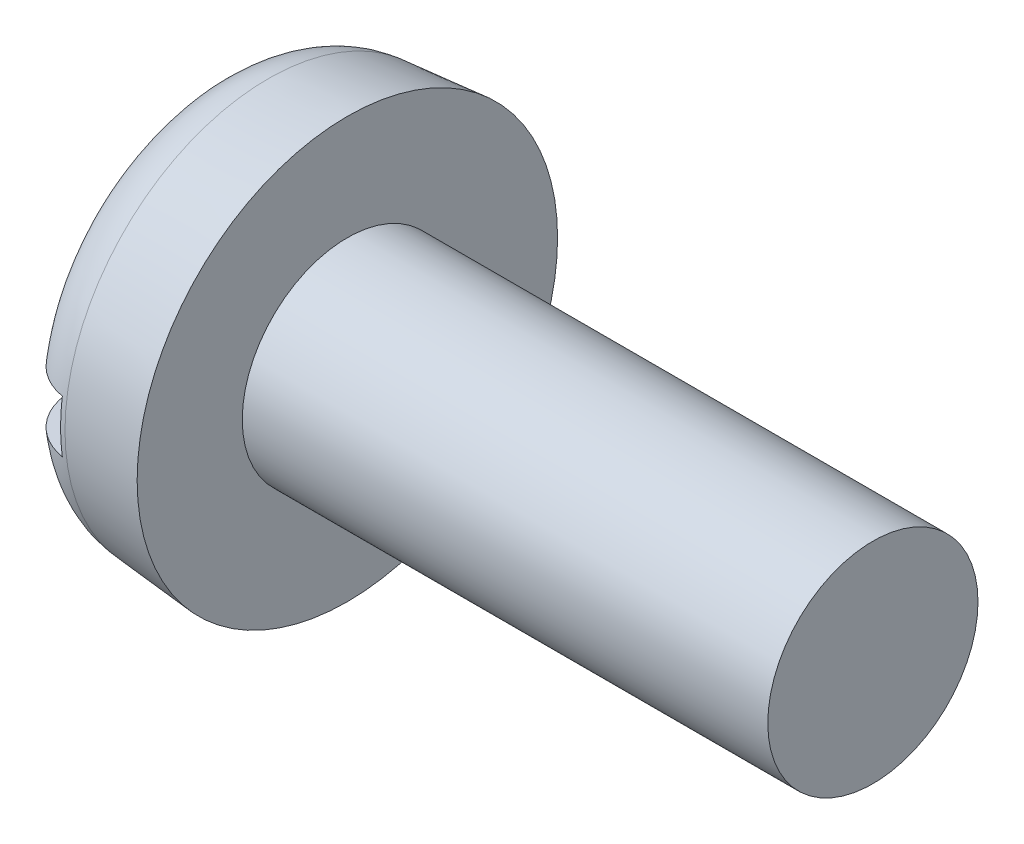
from build123d import *

# Parameters (mm, degrees)
FILLET2_R  = 0.6
SKETCH2_W  = 4
SKETCH2_H  = 0.5
SLOT_DEPTH = 0.5


with BuildPart() as part:
    # BodySke → Base-Revolve (revolve)
    with BuildSketch(Plane.XY, mode=Mode.PRIVATE) as base_revolve_sk:
        Polygon((1.3, 1), (1.3, 2), (0, 1.886264737), (0, 0), (6.3, 0), (6.3, 1), align=None)
    revolve(base_revolve_sk.sketch.rotate(Axis((-25.4, 0, 0), (1, 0, 0)), 90), axis=Axis((-25.4, 0, 0), (1, 0, 0)))  # turned: the seam where the file's is

    # Fillet2
    fillet2_edges = [part.edges().sort_by_distance(p)[0] for p in [
        (0, 0, -1.886264737),
    ]]
    fillet(fillet2_edges, radius=FILLET2_R)

    # Sketch2 → Slot (cut)
    with BuildSketch(Plane(origin=(0, 0, 0), x_dir=(0, 0, -1), z_dir=(1, 0, 0))):
        Rectangle(SKETCH2_W, SKETCH2_H)
    extrude(amount=SLOT_DEPTH, mode=Mode.SUBTRACT)


solid = part.part
